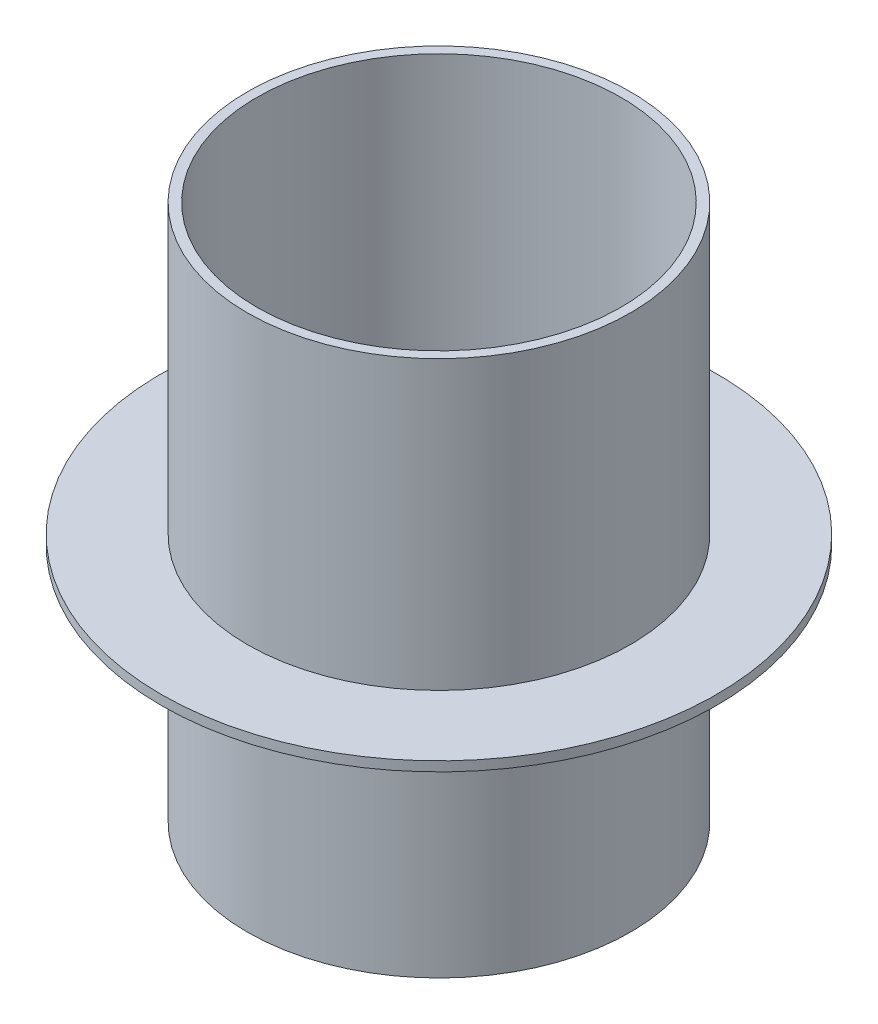
from build123d import *


with BuildPart() as part:
    # 草图1 → 旋转1 (revolve)
    with BuildSketch(Plane.XY):
        Polygon((40, 112), (40, 52), (58, 52), (58, 50), (40, 50), (40, 0), (38, 0), (38, 50), (38, 112), align=None)
    revolve(axis=Axis((0, 71.224758296, 0), (0, -1, 0)))


solid = part.part
